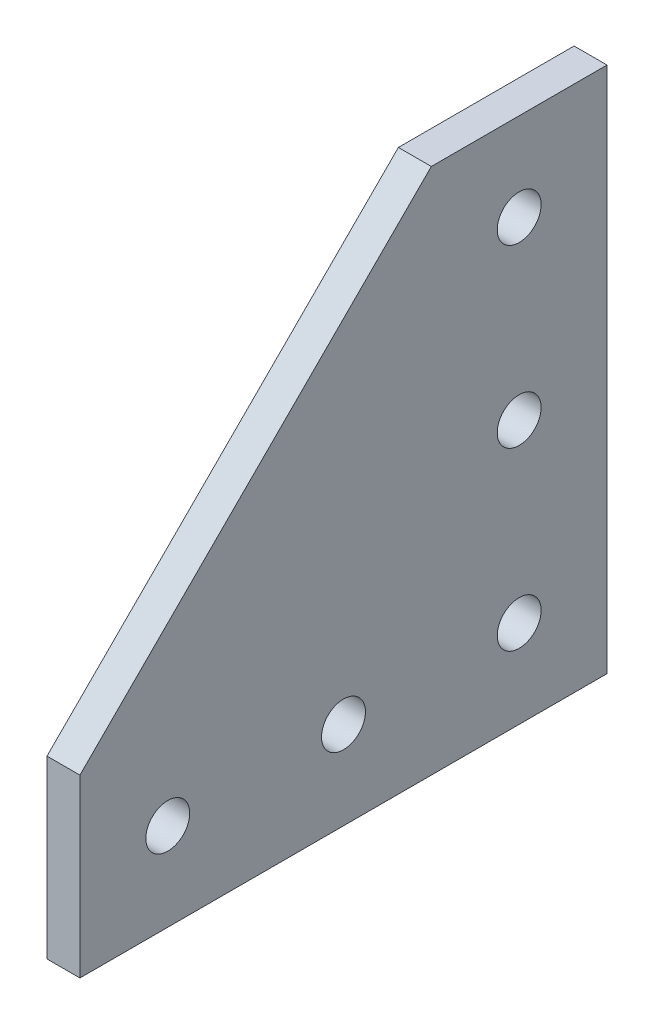
from build123d import *

# Parameters (mm, degrees)
SKETCH1_R           = 3.175
BOSS_EXTRUDE1_DEPTH = 4.7625


with BuildPart() as part:
    # Sketch1 → Boss-Extrude1 (new body)
    with BuildSketch(Plane(origin=(0, 0, 0), x_dir=(0, 0, -1), z_dir=(1, 0, 0))):
        Polygon((0, 0), (-76.2, 0), (-76.2, 25.4), (-25.4, 76.2), (0, 76.2), align=None)
        with Locations((-12.7, 12.7)):
            Circle(SKETCH1_R, mode=Mode.SUBTRACT)
        with Locations((-12.7, 38.1)):
            Circle(SKETCH1_R, mode=Mode.SUBTRACT)
        with Locations((-12.7, 63.5)):
            Circle(SKETCH1_R, mode=Mode.SUBTRACT)
        with Locations((-38.1, 12.7)):
            Circle(SKETCH1_R, mode=Mode.SUBTRACT)
        with Locations((-63.5, 12.7)):
            Circle(SKETCH1_R, mode=Mode.SUBTRACT)
    extrude(amount=BOSS_EXTRUDE1_DEPTH)


solid = part.part
